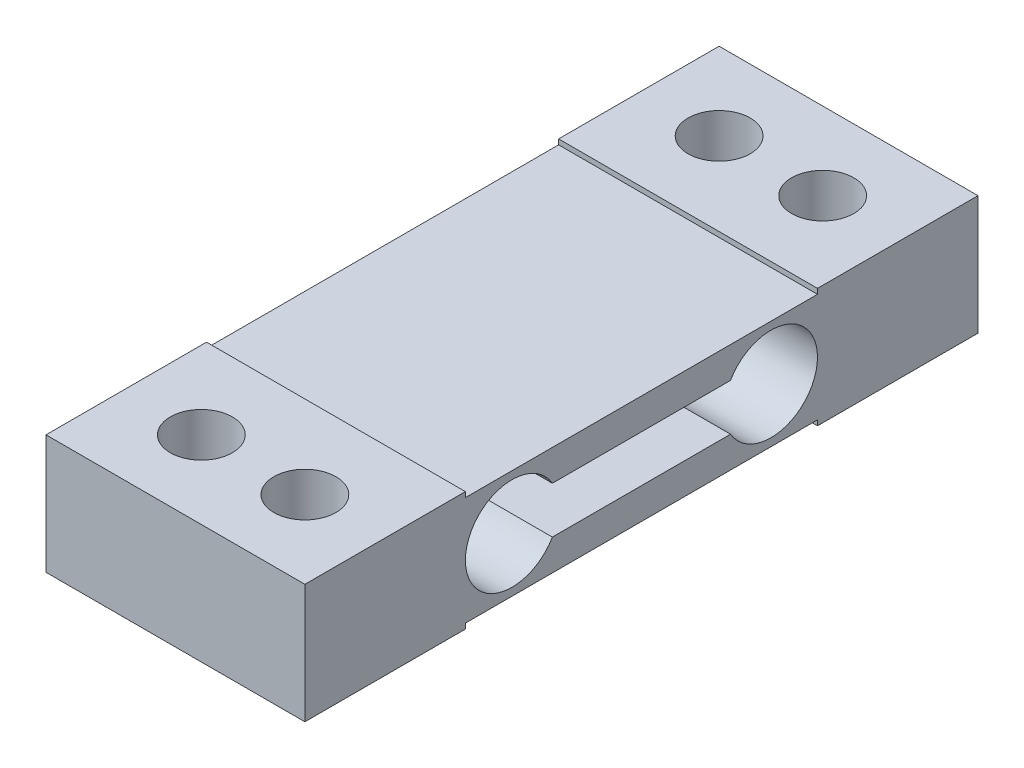
from build123d import *

# Parameters (mm, degrees)
SKETCH2_W           = 130
SKETCH2_H           = 23
BOSS_EXTRUDE1_DEPTH = 50
SKETCH3_R           = 6
CUT_EXTRUDE1_DEPTH  = 23
SKETCH4_W           = 50
SKETCH4_H           = 68
CUT_EXTRUDE3_DEPTH  = 1
SKETCH5_W           = 50
SKETCH5_H           = 68
CUT_EXTRUDE4_DEPTH  = 1


with BuildPart() as part:
    # Sketch2 → Boss-Extrude1 (new body)
    with BuildSketch(Plane(origin=(0, 0, 0), x_dir=(0, 0, -1), z_dir=(1, 0, 0))):
        with Locations((65, 11.5)):
            Rectangle(SKETCH2_W, SKETCH2_H)
        with BuildLine():
            Line((82.205771366, 16), (47.794228634, 16))
            ThreePointArc((47.794228634, 16), (31, 11.5), (47.794228634, 7))
            Line((47.794228634, 7), (82.205771366, 7))
            ThreePointArc((82.205771366, 7), (99, 11.5), (82.205771366, 16))
        make_face(mode=Mode.SUBTRACT)
    extrude(amount=BOSS_EXTRUDE1_DEPTH)

    # Sketch3 → Cut-Extrude1 (cut)
    with BuildSketch(Plane(origin=(0, 23, 0), x_dir=(1, 0, 0), z_dir=(0, 1, 0))):
        with Locations((15, 15)):
            Circle(SKETCH3_R)
        with Locations((35, 15)):
            Circle(SKETCH3_R)
        with Locations((15, 115)):
            Circle(SKETCH3_R)
        with Locations((35, 115)):
            Circle(SKETCH3_R)
    extrude(amount=-CUT_EXTRUDE1_DEPTH, mode=Mode.SUBTRACT)

    # Sketch4 → Cut-Extrude3 (cut)
    with BuildSketch(Plane(origin=(0, 23, 0), x_dir=(1, 0, 0), z_dir=(0, 1, 0))):
        with Locations((25, 65)):
            Rectangle(SKETCH4_W, SKETCH4_H)
    extrude(amount=-CUT_EXTRUDE3_DEPTH, mode=Mode.SUBTRACT)

    # Sketch5 → Cut-Extrude4 (cut)
    with BuildSketch(Plane.XZ):
        with Locations((25, -65)):
            Rectangle(SKETCH5_W, SKETCH5_H)
    extrude(amount=-CUT_EXTRUDE4_DEPTH, mode=Mode.SUBTRACT)


solid = part.part
